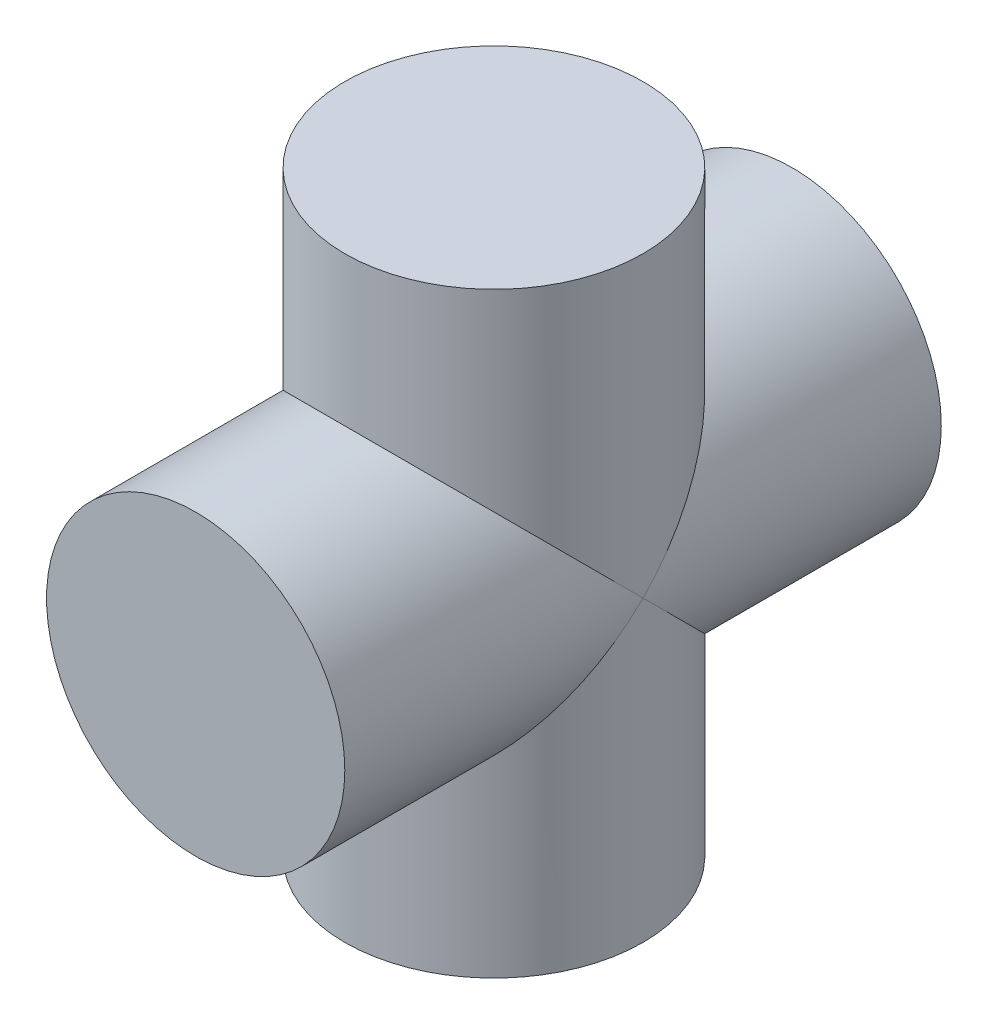
from build123d import *

# Parameters (mm, degrees)
SKETCH1_R           = 5
BOSS_EXTRUDE1_DEPTH = 10
SKETCH2_R           = 5
BOSS_EXTRUDE2_DEPTH = 10


with BuildPart() as part:
    # Sketch1 → Boss-Extrude1 (new body, symmetric)
    with BuildSketch(Plane.XY):
        Circle(SKETCH1_R)
    extrude(amount=BOSS_EXTRUDE1_DEPTH, both=True)

    # Sketch2 → Boss-Extrude2 (add, symmetric)
    with BuildSketch(Plane(origin=(0, 0, 0), x_dir=(1, 0, 0), z_dir=(0, 1, 0))):
        Circle(SKETCH2_R)
    extrude(amount=BOSS_EXTRUDE2_DEPTH, both=True)


solid = part.part
